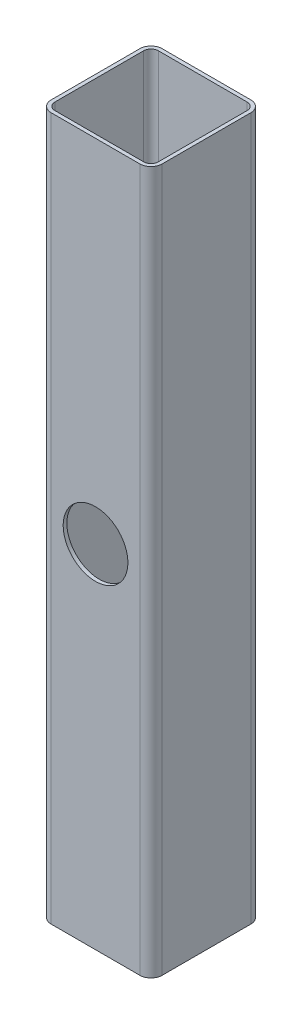
from build123d import *

# Parameters (mm, degrees)
BOSS_EXTRUDE1_DEPTH = 190
SHELL1_T            = -2
SKETCH3_R           = 17.5
CUT_EXTRUDE2_DEPTH  = 61


with BuildPart() as part:
    # Sketch1 → Boss-Extrude1 (new body, symmetric)
    with BuildSketch(Plane(origin=(0, 0, 0), x_dir=(1, 0, 0), z_dir=(0, 1, 0))):
        with BuildLine():
            Line((-24, -30), (24, -30))
            ThreePointArc((24, -30), (28.242640687, -28.242640687), (30, -24))
            Line((30, -24), (30, 24))
            ThreePointArc((30, 24), (28.242640687, 28.242640687), (24, 30))
            Line((24, 30), (-24, 30))
            ThreePointArc((-24, 30), (-28.242640687, 28.242640687), (-30, 24))
            Line((-30, 24), (-30, -24))
            ThreePointArc((-30, -24), (-28.242640687, -28.242640687), (-24, -30))
        make_face()
    extrude(amount=BOSS_EXTRUDE1_DEPTH, both=True)

    # Shell1
    shell1_openings = [part.faces().sort_by_distance(p)[0] for p in [
        (0, 190, 0),
        (0, -190, 0),
    ]]
    offset(amount=SHELL1_T, openings=shell1_openings, kind=Kind.INTERSECTION)

    # Sketch3 → Cut-Extrude2 (cut, through all)
    with BuildSketch(Plane(origin=(0, 0, -30), x_dir=(-1, 0, 0), z_dir=(0, 0, -1))):
        Circle(SKETCH3_R)
    extrude(amount=-CUT_EXTRUDE2_DEPTH, mode=Mode.SUBTRACT)


solid = part.part
